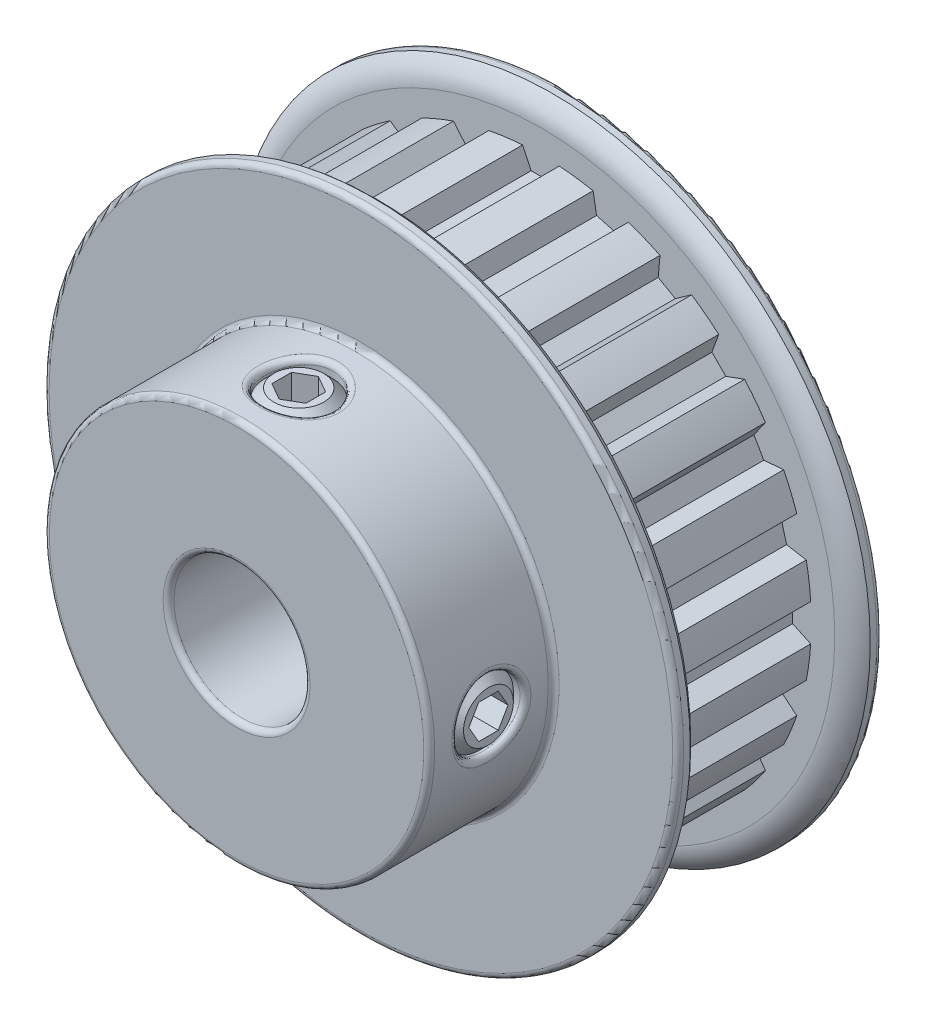
from build123d import *

# Parameters (mm, degrees)
CUT_EXTRUDE1_START = 1.1049
CUT_EXTRUDE1_DEPTH = 10.922
CIRPATTERN1_COUNT  = 24
SKETCH4_R          = 2.38125
CUT_EXTRUDE2_DEPTH = 34.470791572
CUT_EXTRUDE3_DEPTH = 1.7859375
CIRPATTERN2_COUNT  = 2
CIRPATTERN2_ANGLE  = 90
FILLET1_R          = 0.381


with BuildPart() as part:
    # Sketch2 → Revolve1 (revolve)
    with BuildSketch(Plane(origin=(0, 0, 0), x_dir=(0, 0, -1), z_dir=(1, 0, 0)), mode=Mode.PRIVATE) as revolve1_sk:
        with BuildLine():
            Line((-11.5062, 4.7625), (11.5062, 4.7625))
            Line((11.5062, 4.7625), (11.5062, 22.225))
            Line((11.5062, 22.225), (10.66165, 22.225))
            ThreePointArc((10.66165, 22.225), (10.040613123, 21.506254819), (9.8171, 20.583041234))
            Line((9.8171, 20.583041234), (9.8171, 18.941082468))
            Line((9.8171, 18.941082468), (-1.1049, 18.941082468))
            Line((-1.1049, 18.941082468), (-1.1049, 20.583041234))
            ThreePointArc((-1.1049, 20.583041234), (-1.328413123, 21.506254819), (-1.94945, 22.225))
            Line((-1.94945, 22.225), (-2.794, 22.225))
            Line((-2.794, 22.225), (-2.794, 13.5001))
            Line((-2.794, 13.5001), (-11.5062, 13.5001))
            Line((-11.5062, 13.5001), (-11.5062, 4.7625))
        make_face()
    revolve(revolve1_sk.sketch.rotate(Axis((0, 0, 11.5062), (0, 0, -1)), 90), axis=Axis((0, 0, 11.5062), (0, 0, -1)))

    # Sketch3 → Cut-Extrude1 (cut)
    with BuildSketch(Plane.XY.offset(CUT_EXTRUDE1_START)):
        with BuildLine():
            Line((-0.690489274, 17.6276), (0.690489274, 17.6276))
            Line((0.690489274, 17.6276), (1.2827, 18.8976))
            ThreePointArc((1.2827, 18.8976), (0, 18.941082468), (-1.2827, 18.8976))
            Line((-1.2827, 18.8976), (-0.690489274, 17.6276))
        make_face()
    cut_extrude1 = extrude(amount=-CUT_EXTRUDE1_DEPTH, mode=Mode.SUBTRACT)

    # CirPattern1: Cut-Extrude1 ×24 about axis
    cirpattern1_axis = Axis((0, 0, 0), (0, 0, 1))
    for i in range(1, CIRPATTERN1_COUNT):
        add(cut_extrude1.rotate(cirpattern1_axis, i * 360 / CIRPATTERN1_COUNT), mode=Mode.SUBTRACT)

    # Sketch4 → Cut-Extrude2 (cut, through all)
    with BuildSketch(Plane(origin=(0, 0, 0), x_dir=(1, 0, 0), z_dir=(0, 1, 0))):
        with Locations(Location((0, -7.1501, 0), (0, 0, 90))):
            Circle(SKETCH4_R)
    cut_extrude2 = extrude(amount=CUT_EXTRUDE2_DEPTH, mode=Mode.SUBTRACT)

    # Sketch5 → Revolve2 (revolve)
    with BuildSketch(Plane.XY.offset(7.1501), mode=Mode.PRIVATE) as revolve2_sk:
        Polygon((0, 13.288429119), (0, 4.7625), (-1.74625, 4.7625), (-2.38125, 5.3975), (-2.38125, 12.653429119), (-1.74625, 13.288429119), align=None)
    revolve2 = revolve(revolve2_sk.sketch.rotate(Axis((0, 0, 7.1501), (0, 1, 0)), 270), axis=Axis((0, 0, 7.1501), (0, 1, 0)))

    # Sketch6 → Cut-Extrude3 (cut)
    with BuildSketch(Plane(origin=(0, 13.288429119, 0), x_dir=(-1, 0, 0), z_dir=(0, -1, 0))):
        Polygon((0, -5.775284671), (-1.190625, -6.462692336), (-1.190625, -7.837507664), (0, -8.524915329), (1.190625, -7.837507664), (1.190625, -6.462692336), align=None)
    cut_extrude3 = extrude(amount=CUT_EXTRUDE3_DEPTH, mode=Mode.SUBTRACT)

    # CirPattern2: Cut-Extrude2, Revolve2, Cut-Extrude3 ×2 about axis
    cirpattern2_axis = Axis((0, 0, 0), (0, 0, -1))
    add([cut_extrude2.rotate(cirpattern2_axis, i * CIRPATTERN2_ANGLE / (CIRPATTERN2_COUNT - 1)) for i in range(1, CIRPATTERN2_COUNT)], mode=Mode.SUBTRACT)
    add([revolve2.rotate(cirpattern2_axis, i * CIRPATTERN2_ANGLE / (CIRPATTERN2_COUNT - 1)) for i in range(1, CIRPATTERN2_COUNT)])
    add([cut_extrude3.rotate(cirpattern2_axis, i * CIRPATTERN2_ANGLE / (CIRPATTERN2_COUNT - 1)) for i in range(1, CIRPATTERN2_COUNT)], mode=Mode.SUBTRACT)

    # Fillet1
    fillet1_edges = [part.edges().sort_by_distance(p)[0] for p in [
        (-22.225, 0, -11.5062),
        (-4.7625, 0, -11.5062),
        (-4.7625, 0, 11.5062),
        (-1e-09, 13.500099999, 9.531350016),
        (13.288429119, -2.38125, 7.1501),
        (-13.5001, 0, 11.5062),
        (-13.5001, 0, 2.794),
        (-22.225, 0, 2.794),
    ]]
    fillet(fillet1_edges, radius=FILLET1_R)


solid = part.part
